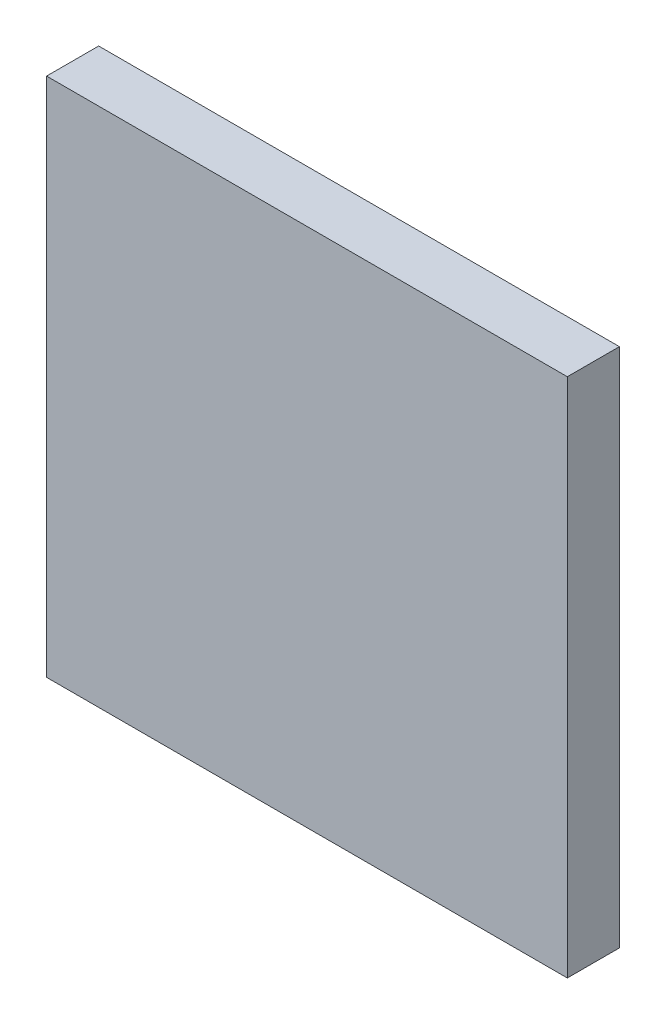
from build123d import *

# Parameters (mm, degrees)
SKETCH1_W           = 100
SKETCH1_H           = 100
BOSS_EXTRUDE1_DEPTH = 10


with BuildPart() as part:
    # Sketch1 → Boss-Extrude1 (new body)
    with BuildSketch(Plane.XY):
        Rectangle(SKETCH1_W, SKETCH1_H)
    extrude(amount=BOSS_EXTRUDE1_DEPTH)


solid = part.part
